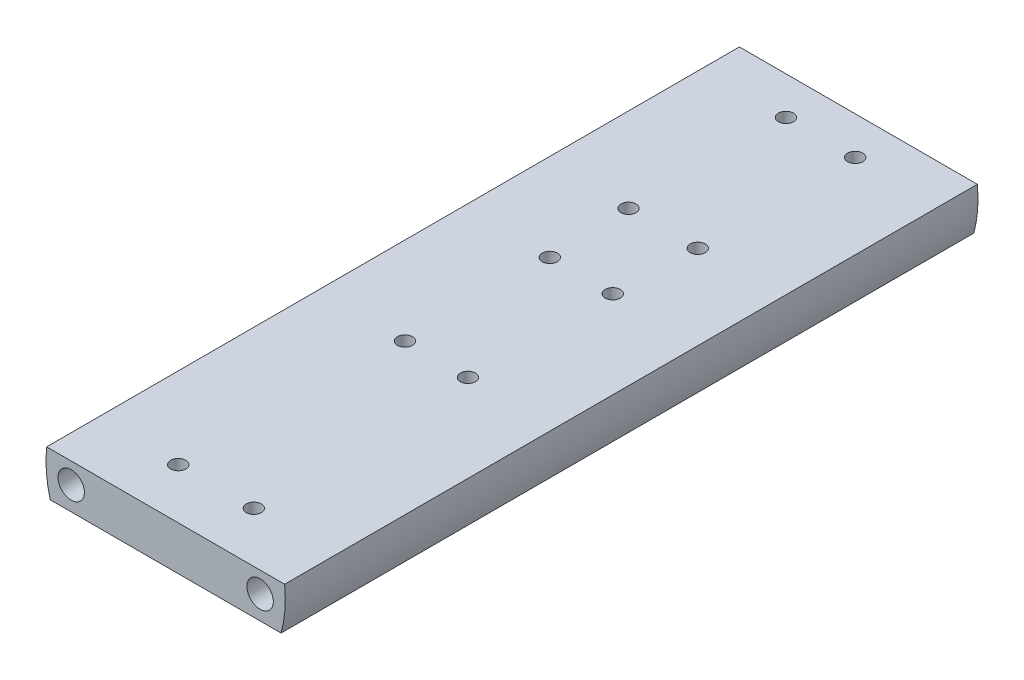
from build123d import *

# Parameters (mm, degrees)
SKETCH1_R           = 2.667
BOSS_EXTRUDE1_DEPTH = 139.7
SKETCH2_R           = 1.524
CUT_EXTRUDE1_DEPTH  = 5.08
SKETCH5_R           = 1.524
CUT_EXTRUDE2_DEPTH  = 5.08


with BuildPart() as part:
    # Sketch1 → Boss-Extrude1 (new body)
    with BuildSketch(Plane.XY):
        with BuildLine():
            ThreePointArc((0.134056593, 2.54), (0.077982482, -1.938389365), (0.85051547, -6.35))
            Line((0.85051547, -6.35), (47.40948453, -6.35))
            ThreePointArc((47.40948453, -6.35), (48.182017518, -1.938389365), (48.125943407, 2.54))
            Line((48.125943407, 2.54), (0.134056593, 2.54))
        make_face()
        with Locations((43.18, -1.634887509)):
            Circle(SKETCH1_R, mode=Mode.SUBTRACT)
        with Locations((5.08, -1.634887509)):
            Circle(SKETCH1_R, mode=Mode.SUBTRACT)
    extrude(amount=BOSS_EXTRUDE1_DEPTH)

    # Sketch2 → Cut-Extrude1 (cut)
    with BuildSketch(Plane(origin=(0, 2.54, 0), x_dir=(1, 0, 0), z_dir=(0, 1, 0))):
        with Locations((17.145, -7.62)):
            Circle(SKETCH2_R)
        with Locations((31.115, -7.62)):
            Circle(SKETCH2_R)
        with Locations((31.115, -39.37)):
            Circle(SKETCH2_R)
        with Locations((17.145, -39.37)):
            Circle(SKETCH2_R)
        with Locations((17.78, -55.88)):
            Circle(SKETCH2_R)
        with Locations((30.48, -55.88)):
            Circle(SKETCH2_R)
        with Locations((30.48, -85.09)):
            Circle(SKETCH2_R)
        with Locations((17.78, -85.09)):
            Circle(SKETCH2_R)
        with Locations((16.51, -129.54)):
            Circle(SKETCH2_R)
        with Locations((31.75, -129.54)):
            Circle(SKETCH2_R)
    extrude(amount=-CUT_EXTRUDE1_DEPTH, mode=Mode.SUBTRACT)

    # Sketch5 → Cut-Extrude2 (cut)
    with BuildSketch(Plane.XZ.offset(6.35)):
        with Locations((17.78, 125.73)):
            Circle(SKETCH5_R)
        with Locations((30.48, 125.73)):
            Circle(SKETCH5_R)
        with Locations((30.48, 100.33)):
            Circle(SKETCH5_R)
        with Locations((17.78, 100.33)):
            Circle(SKETCH5_R)
    extrude(amount=-CUT_EXTRUDE2_DEPTH, mode=Mode.SUBTRACT)


solid = part.part
